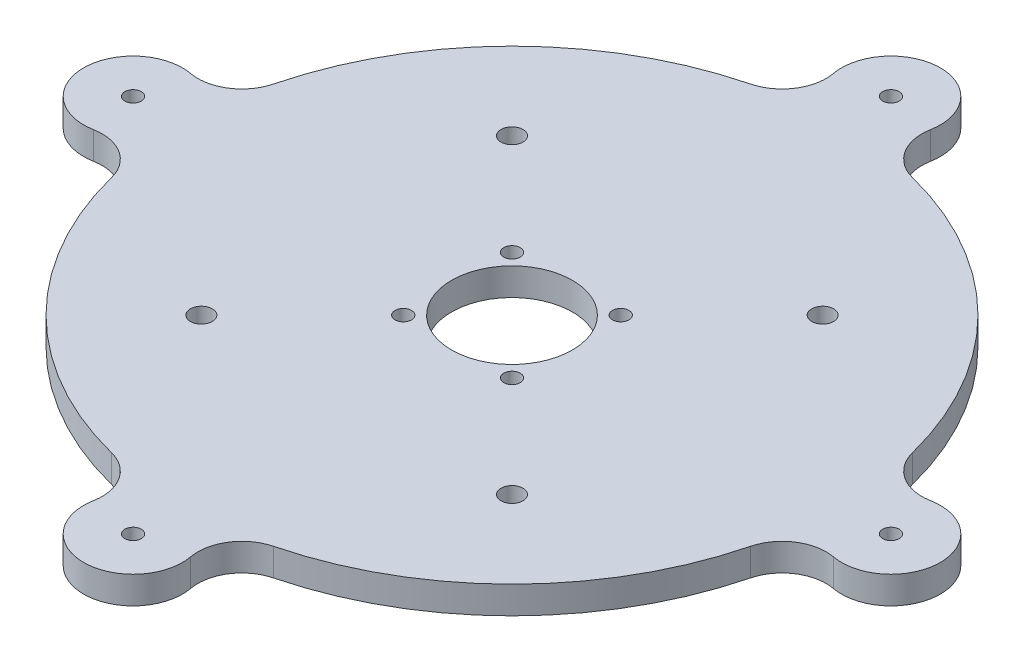
from build123d import *

# Parameters (mm, degrees)
SKETCH1_R           = 1.5
SKETCH1_R_2         = 11
SKETCH1_R_3         = 2
BOSS_EXTRUDE1_DEPTH = 5


with BuildPart() as part:
    # Sketch1 → Boss-Extrude1 (new body)
    with BuildSketch(Plane(origin=(0, 0, 0), x_dir=(1, 0, 0), z_dir=(0, 1, 0))):
        with BuildLine():
            ThreePointArc((14.750626914, -58.158567775), (9.981753959, -61.596635254), (8.850376149, -67.3657289))
            ThreePointArc((8.850376149, -67.3657289), (0, -78), (-8.850376149, -67.3657289))
            ThreePointArc((-8.850376149, -67.3657289), (-9.981753959, -61.596635254), (-14.750626914, -58.158567775))
            ThreePointArc((-14.750626914, -58.158567775), (-42.426406871, -42.426406871), (-58.158567775, -14.750626914))
            ThreePointArc((-58.158567775, -14.750626914), (-61.596635254, -9.981753959), (-67.3657289, -8.850376149))
            ThreePointArc((-67.3657289, -8.850376149), (-78, 0), (-67.3657289, 8.850376149))
            ThreePointArc((-67.3657289, 8.850376149), (-61.596635254, 9.981753959), (-58.158567775, 14.750626914))
            ThreePointArc((-58.158567775, 14.750626914), (-42.426406871, 42.426406871), (-14.750626914, 58.158567775))
            ThreePointArc((-14.750626914, 58.158567775), (-9.981753959, 61.596635254), (-8.850376149, 67.3657289))
            ThreePointArc((-8.850376149, 67.3657289), (0, 78), (8.850376149, 67.3657289))
            ThreePointArc((8.850376149, 67.3657289), (9.981753959, 61.596635254), (14.750626914, 58.158567775))
            ThreePointArc((14.750626914, 58.158567775), (42.426406871, 42.426406871), (58.158567775, 14.750626914))
            ThreePointArc((58.158567775, 14.750626914), (61.596635254, 9.981753959), (67.3657289, 8.850376149))
            ThreePointArc((67.3657289, 8.850376149), (78, 0), (67.3657289, -8.850376149))
            ThreePointArc((67.3657289, -8.850376149), (61.596635254, -9.981753959), (58.158567775, -14.750626914))
            ThreePointArc((58.158567775, -14.750626914), (42.426406871, -42.426406871), (14.750626914, -58.158567775))
        make_face()
        with Locations((0, -69)):
            Circle(SKETCH1_R, mode=Mode.SUBTRACT)
        with Locations((-69, 0)):
            Circle(SKETCH1_R, mode=Mode.SUBTRACT)
        with Locations((0, 69)):
            Circle(SKETCH1_R, mode=Mode.SUBTRACT)
        with Locations((69, 0)):
            Circle(SKETCH1_R, mode=Mode.SUBTRACT)
        Circle(SKETCH1_R_2, mode=Mode.SUBTRACT)
        with Locations((9.899494937, 9.899494937)):
            Circle(SKETCH1_R, mode=Mode.SUBTRACT)
        with Locations((9.899494937, -9.899494937)):
            Circle(SKETCH1_R, mode=Mode.SUBTRACT)
        with Locations((-9.899494937, -9.899494937)):
            Circle(SKETCH1_R, mode=Mode.SUBTRACT)
        with Locations((-9.899494937, 9.899494937)):
            Circle(SKETCH1_R, mode=Mode.SUBTRACT)
        with Locations((28.284271247, 28.284271247)):
            Circle(SKETCH1_R_3, mode=Mode.SUBTRACT)
        with Locations((28.284271247, -28.284271247)):
            Circle(SKETCH1_R_3, mode=Mode.SUBTRACT)
        with Locations((-28.284271247, -28.284271247)):
            Circle(SKETCH1_R_3, mode=Mode.SUBTRACT)
        with Locations((-28.284271247, 28.284271247)):
            Circle(SKETCH1_R_3, mode=Mode.SUBTRACT)
    extrude(amount=BOSS_EXTRUDE1_DEPTH)


solid = part.part
